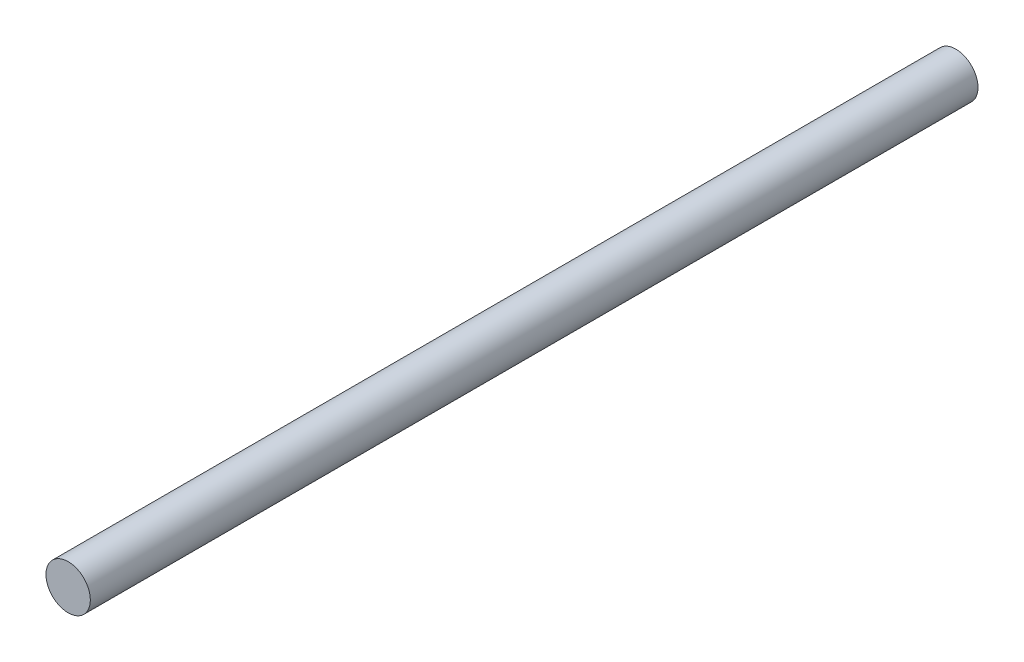
from build123d import *

# Parameters (mm, degrees)
SKETCH_1_R      = 4
EXTRUDE_1_DEPTH = 160


with BuildPart() as part:
    # 草图1 → 凸台-拉伸1 (new body)
    with BuildSketch(Plane.XY):
        Circle(SKETCH_1_R)
    extrude(amount=EXTRUDE_1_DEPTH)


solid = part.part
